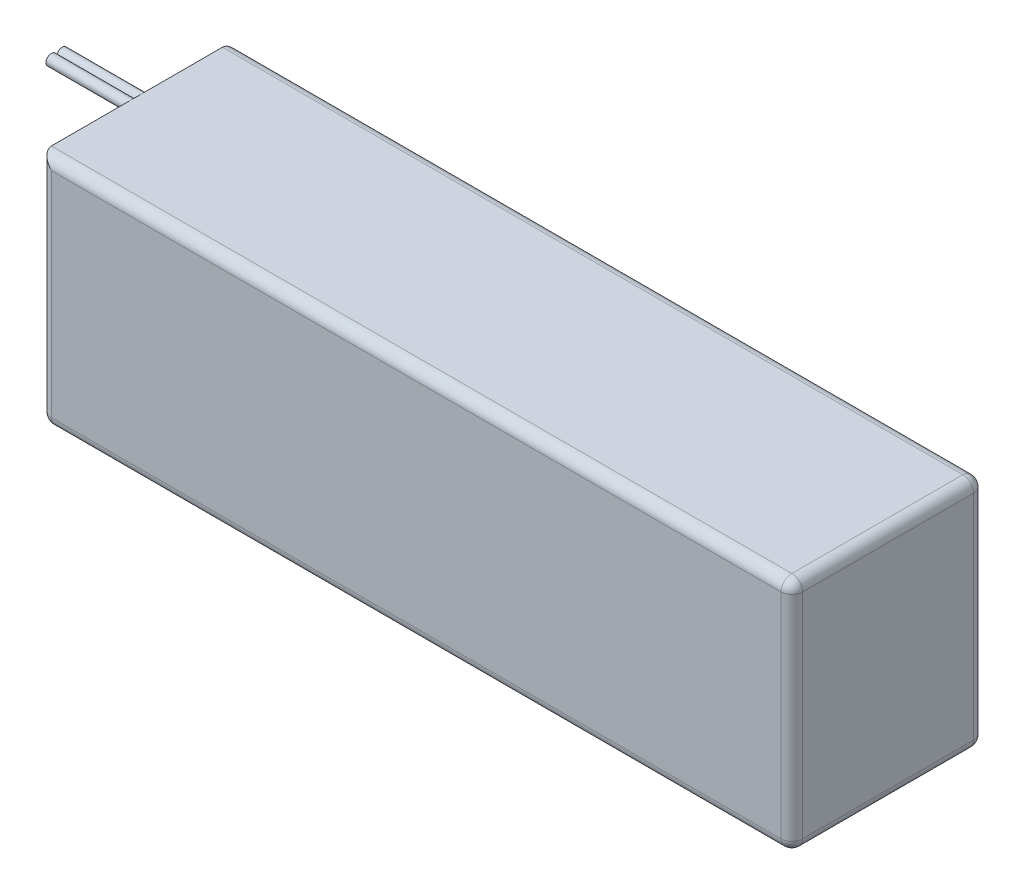
from build123d import *

# Parameters (mm, degrees)
SKETCH1_W             = 140.5
SKETCH1_H             = 44
BOSS_EXTRUDE1_DEPTH   = 36
SKETCH2_R             = 1
BOSS_EXTRUDE4_DEPTH   = 15
BOSS_EXTRUDE4_2_DEPTH = 15
FILLET1_R             = 2


with BuildPart() as part:
    # Sketch1 → Boss-Extrude1 (new body)
    with BuildSketch(Plane.XY):
        Rectangle(SKETCH1_W, SKETCH1_H)
    extrude(amount=BOSS_EXTRUDE1_DEPTH)

    # Fillet1
    fillet1_edges = [part.edges().sort_by_distance(p)[0] for p in [
        (-70.25, 0, 36),
        (0, -22, 36),
        (70.25, 0, 36),
        (0, -22, 0),
        (-70.25, 0, 0),
        (0, 22, 0),
        (70.25, 0, 0),
        (70.25, -22, 18),
        (-70.25, -22, 18),
        (70.25, 22, 18),
        (0, 22, 36),
    ]]
    fillet(fillet1_edges, radius=FILLET1_R)


with BuildPart() as body_2:
    # Sketch2 → Boss-Extrude4 (new body)
    with BuildSketch(Plane.ZY.offset(70.25)):
        with Locations((16.995, 21)):
            Circle(SKETCH2_R)
    extrude(amount=BOSS_EXTRUDE4_DEPTH)


with BuildPart() as body_3:
    # Sketch2 → Boss-Extrude4 2 (new body)
    with BuildSketch(Plane.ZY.offset(70.25)):
        with Locations((19.005, 21)):
            Circle(SKETCH2_R)
    extrude(amount=BOSS_EXTRUDE4_2_DEPTH)


solid = Compound([part.part, body_2.part, body_3.part])
